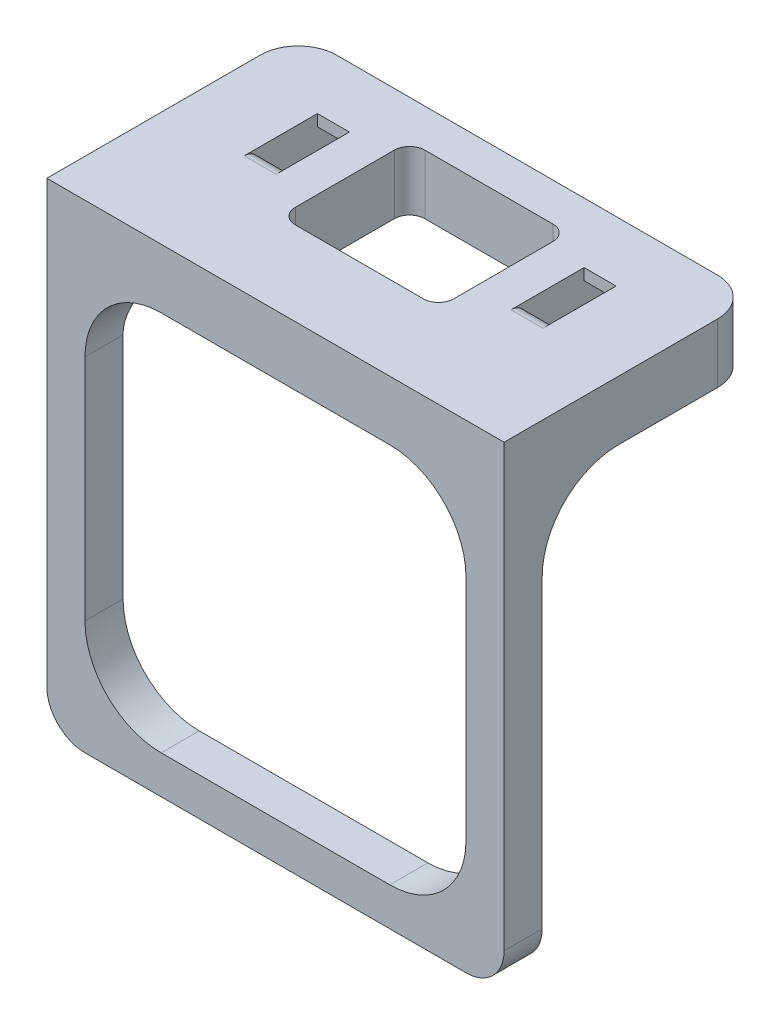
from build123d import *

# Parameters (mm, degrees)
SKETCH1_W               = 60
SKETCH1_H               = 33
BOSS_EXTRUDE1_DEPTH     = 10
SKETCH2_W               = 4.2
SKETCH2_H               = 11
CUT_EXTRUDE1_DEPTH      = 5.8
BOSS_EXTRUDE2_START     = -45.4
BOSS_EXTRUDE2_DEPTH     = 55.8
SKETCH4_W               = 33
SKETCH4_H               = 2.2
CUT_EXTRUDE2_DEPTH      = 1
CUT_EXTRUDE2_DEPTH_BACK = 61
FILLET1_R               = 2
SKETCH7_W               = 20.8
SKETCH7_H               = 17
CUT_EXTRUDE4_DEPTH      = 16
FILLET2_R               = 2
BOSS_EXTRUDE4_START     = -7.8
SKETCH5_W               = 60
SKETCH5_H               = 5
BOSS_EXTRUDE4_DEPTH     = 55
SKETCH8_W               = 50
SKETCH8_H               = 50
CUT_EXTRUDE5_DEPTH      = 52.15
FILLET3_R               = 10
FILLET4_R               = 5
FILLET6_R               = 5


with BuildPart() as part:
    # Sketch1 → Boss-Extrude1 (new body)
    with BuildSketch(Plane(origin=(0, 0, 0), x_dir=(1, 0, 0), z_dir=(0, 1, 0))):
        with Locations((30, 16.5)):
            Rectangle(SKETCH1_W, SKETCH1_H)
    extrude(amount=BOSS_EXTRUDE1_DEPTH)

    # Sketch2 → Cut-Extrude1 (cut)
    with BuildSketch(Plane(origin=(0, 10, 0), x_dir=(1, 0, 0), z_dir=(0, 1, 0))):
        with Locations((12.5, 23)):
            Rectangle(SKETCH2_W, SKETCH2_H)
        with Locations((47.5, 23)):
            Rectangle(SKETCH2_W, SKETCH2_H)
    extrude(amount=-CUT_EXTRUDE1_DEPTH, mode=Mode.SUBTRACT)

    # Sketch3 → Boss-Extrude2 (add)
    with BuildSketch(Plane.ZY.offset(-14.6).offset(BOSS_EXTRUDE2_START)):
        Polygon((-28.5, 5.85), (-25.1, 8.5), (-25.1, 10), (-28.5, 10), align=None)
    extrude(amount=BOSS_EXTRUDE2_DEPTH)

    # Sketch4 → Cut-Extrude2 (cut, two sides)
    with BuildSketch(Plane(origin=(60, 0, 0), x_dir=(0, 0, -1), z_dir=(1, 0, 0))) as cut_extrude2_sk:
        with Locations((16.5, 1.1)):
            Rectangle(SKETCH4_W, SKETCH4_H)
    extrude(amount=CUT_EXTRUDE2_DEPTH, mode=Mode.SUBTRACT)
    extrude(cut_extrude2_sk.sketch, amount=-CUT_EXTRUDE2_DEPTH_BACK, mode=Mode.SUBTRACT)

    # Fillet1
    fillet1_edges = [part.edges().sort_by_distance(p)[0] for p in [
        (12.5, 10, -17.5),
        (47.5, 10, -17.5),
    ]]
    fillet(fillet1_edges, radius=FILLET1_R)

    # Sketch7 → Cut-Extrude4 (cut)
    with BuildSketch(Plane(origin=(0, 10, 0), x_dir=(1, 0, 0), z_dir=(0, 1, 0))):
        with Locations((30, 19.5)):
            Rectangle(SKETCH7_W, SKETCH7_H)
    extrude(amount=-CUT_EXTRUDE4_DEPTH, mode=Mode.SUBTRACT)

    # Fillet2
    fillet2_edges = [part.edges().sort_by_distance(p)[0] for p in [
        (19.6, 6.1, -11),
        (19.6, 6.1, -28),
        (40.4, 6.1, -28),
        (40.4, 6.1, -11),
    ]]
    fillet(fillet2_edges, radius=FILLET2_R)

    # Sketch5 → Boss-Extrude4 (add)
    with BuildSketch(Plane(origin=(0, 10, 0), x_dir=(1, 0, 0), z_dir=(0, 1, 0)).offset(BOSS_EXTRUDE4_START)):
        with Locations((30, 2.5)):
            Rectangle(SKETCH5_W, SKETCH5_H)
    extrude(amount=-BOSS_EXTRUDE4_DEPTH)

    # Sketch8 → Cut-Extrude5 (cut)
    with BuildSketch(Plane(origin=(0, 0, -5), x_dir=(-1, 0, 0), z_dir=(0, 0, -1))):
        with Locations((-30, -22.8)):
            Rectangle(SKETCH8_W, SKETCH8_H)
    extrude(amount=-CUT_EXTRUDE5_DEPTH, mode=Mode.SUBTRACT)

    # Fillet3
    fillet3_edges = [part.edges().sort_by_distance(p)[0] for p in [
        (57.5, 2.2, -5),
        (2.5, 2.2, -5),
        (55, -47.8, -2.5),
        (55, 2.2, -2.5),
        (5, 2.2, -2.5),
        (5, -47.8, -2.5),
    ]]
    fillet(fillet3_edges, radius=FILLET3_R)

    # Fillet4
    fillet4_edges = [part.edges().sort_by_distance(p)[0] for p in [
        (60, -52.8, -2.5),
        (0, -52.8, -2.5),
    ]]
    fillet(fillet4_edges, radius=FILLET4_R)

    # Fillet6
    fillet6_edges = [part.edges().sort_by_distance(p)[0] for p in [
        (0, 6.1, -33),
        (60, 6.1, -33),
    ]]
    fillet(fillet6_edges, radius=FILLET6_R)


solid = part.part
